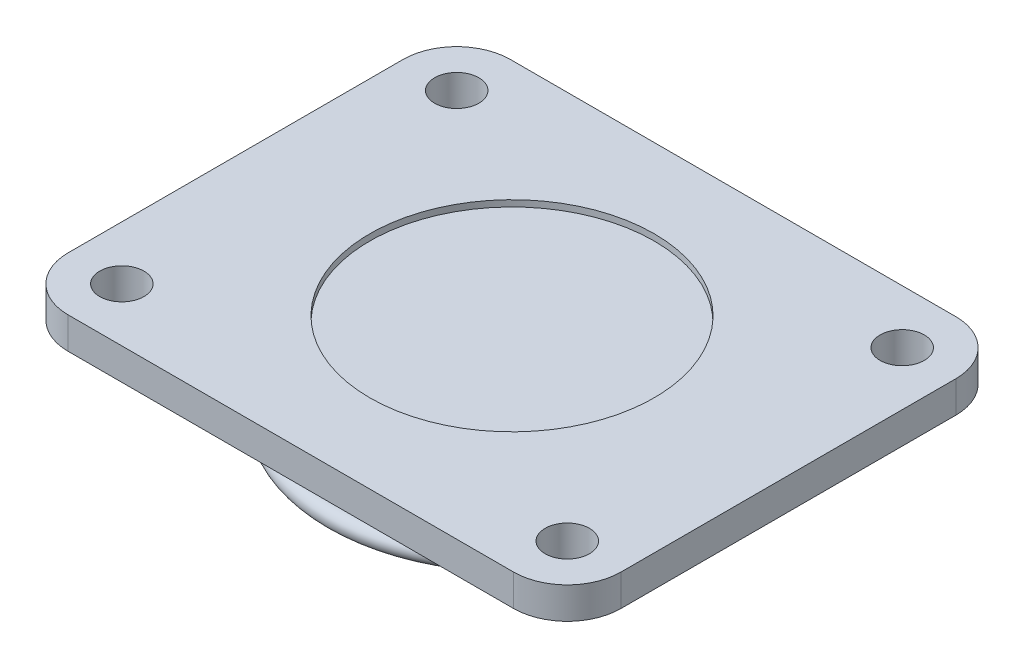
from build123d import *

# Parameters (mm, degrees)
SKETCH1_R           = 7
BOSS_EXTRUDE1_DEPTH = 10
SKETCH2_R           = 45
CUT_EXTRUDE1_DEPTH  = 2
SKETCH3_R           = 56
BOSS_EXTRUDE2_DEPTH = 20
SKETCH4_R           = 3
SKETCH5_R           = 7.5
BOSS_EXTRUDE3_DEPTH = 25
CHAMFER1_SIZE       = 1


with BuildPart() as part:
    # Sketch1 → Boss-Extrude1 (new body)
    with BuildSketch(Plane(origin=(0, 0, 0), x_dir=(1, 0, 0), z_dir=(0, 1, 0))):
        with BuildLine():
            Line((-70.5, -70), (70.5, -70))
            ThreePointArc((70.5, -70), (82.52081528, -65.02081528), (87.5, -53))
            Line((87.5, -53), (87.5, 53))
            ThreePointArc((87.5, 53), (82.52081528, 65.02081528), (70.5, 70))
            Line((70.5, 70), (-70.5, 70))
            ThreePointArc((-70.5, 70), (-82.52081528, 65.02081528), (-87.5, 53))
            Line((-87.5, 53), (-87.5, -53))
            ThreePointArc((-87.5, -53), (-82.52081528, -65.02081528), (-70.5, -70))
        make_face()
        with Locations((70.5, -53)):
            Circle(SKETCH1_R, mode=Mode.SUBTRACT)
        with Locations((70.5, 53)):
            Circle(SKETCH1_R, mode=Mode.SUBTRACT)
        with Locations((-70.5, 53)):
            Circle(SKETCH1_R, mode=Mode.SUBTRACT)
        with Locations((-70.5, -53)):
            Circle(SKETCH1_R, mode=Mode.SUBTRACT)
    extrude(amount=BOSS_EXTRUDE1_DEPTH)

    # Sketch2 → Cut-Extrude1 (cut)
    with BuildSketch(Plane(origin=(0, 10, 0), x_dir=(1, 0, 0), z_dir=(0, 1, 0))):
        Circle(SKETCH2_R)
    extrude(amount=-CUT_EXTRUDE1_DEPTH, mode=Mode.SUBTRACT)

    # Sketch3 → Boss-Extrude2 (add)
    with BuildSketch(Plane.XZ):
        Circle(SKETCH3_R)
    extrude(amount=BOSS_EXTRUDE2_DEPTH)

    # Sketch4 → Revolve1 (revolve)
    with BuildSketch(Plane(origin=(0, 0, 0), x_dir=(0, 0, -1), z_dir=(1, 0, 0))):
        with Locations((-56, -17)):
            Circle(SKETCH4_R)
    revolve(axis=Axis((0, 0, 0), (0, -1, 0)))

    # Sketch5 → Boss-Extrude3 (add)
    with BuildSketch(Plane.XZ.offset(20)):
        Circle(SKETCH5_R)
    extrude(amount=BOSS_EXTRUDE3_DEPTH)

    # Chamfer1
    chamfer1_edges = [part.edges().sort_by_distance(p)[0] for p in [
        (-7.5, -45, 0),
    ]]
    chamfer(chamfer1_edges, length=CHAMFER1_SIZE)


solid = part.part
